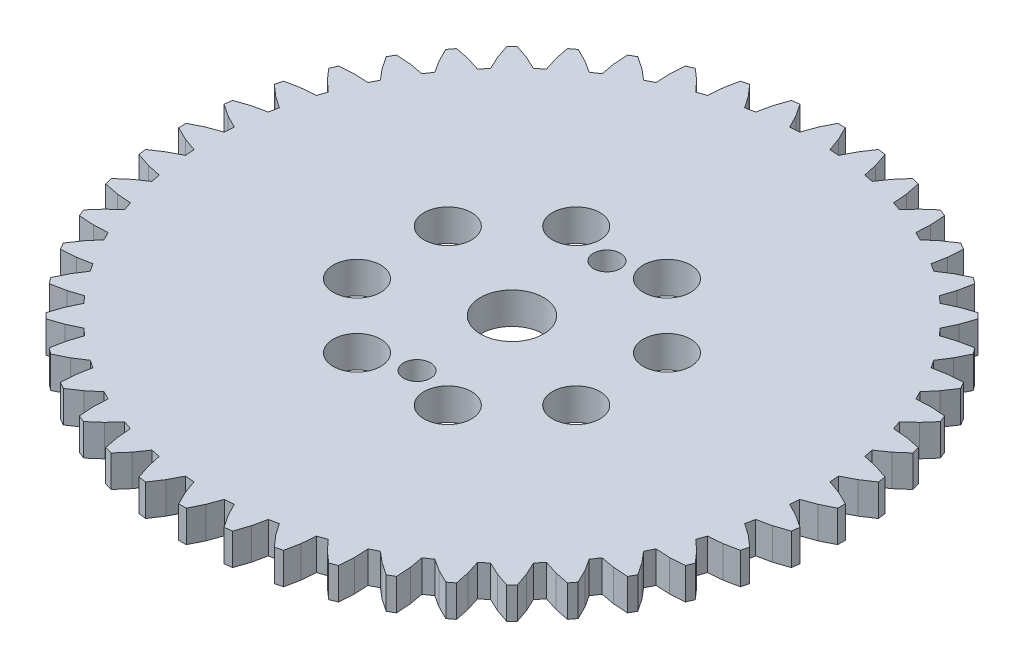
from build123d import *

# Parameters (mm, degrees)
BOSS_EXTRUDE2_DEPTH = 4
CUT_EXTRUDE1_REACH  = 6
SKETCH3_R           = 4
CUT_EXTRUDE2_REACH  = 6
SKETCH4_R           = 1.7
SKETCH5_R           = 3
CUT_EXTRUDE3_DEPTH  = 4
CIRPATTERN1_COUNT   = 8


with BuildPart() as part:
    # Sketch1 → Boss-Extrude2 (new body)
    with BuildSketch(Plane(origin=(0, 0, 0), x_dir=(1, 0, 0), z_dir=(0, 1, 0))):
        Polygon((42.670768214, 7.33199203), (44.364090179, 6.722783745), (46.049296244, 5.897590381), (46.049296244, 4.930501415), (44.364090179, 4.10530805), (42.670768214, 3.496099765), (42.593668553, 2.318392566), (44.192872884, 1.493330462), (45.756080243, 0.455162666), (45.629761993, -0.503548343), (43.851224003, -1.101761341), (42.092976227, -1.484774504), (41.862723156, -2.64232275), (43.340583693, -3.668971144), (44.754826389, -4.902310618), (44.504546088, -5.836412796), (42.663045168, -6.197303661), (40.869846795, -6.347576757), (40.490498727, -7.465069617), (41.821751264, -8.676025199), (43.062944581, -10.083330557), (42.692890512, -10.976722901), (40.819973758, -11.094271266), (39.022455841, -11.009186038), (38.500557723, -12.067643121), (39.662294716, -13.441830895), (40.709232397, -14.999147756), (40.225688377, -15.836645304), (38.353556868, -15.7087561), (36.582480794, -15.389753168), (35.926802973, -16.37097933), (36.899389583, -17.885098897), (37.734007744, -19.56572336), (37.14535034, -20.332928251), (35.305944489, -19.96169562), (33.591678325, -19.414272165), (32.813478148, -20.30164275), (33.58002859, -21.929645586), (34.188189572, -23.704910872), (33.504368159, -24.388732285), (31.729102873, -23.780570839), (30.101100501, -23.01402086), (29.213729452, -23.792221038), (29.761152907, -25.506486738), (30.132385538, -27.345893053), (29.365180648, -27.934549993), (27.684556184, -27.099932296), (26.170436617, -26.127345222), (25.189210455, -26.783023506), (25.508213387, -28.554099581), (25.636103055, -30.426230626), (24.798605043, -30.90977511), (23.241288182, -29.862837428), (21.867100409, -28.701100436), (20.808643325, -29.222998554), (20.893728553, -31.020516471), (20.776180188, -32.893433225), (19.882787844, -33.263487293), (18.475482486, -32.022293977), (17.264527368, -30.69104144), (16.147034045, -31.070389508), (15.996760948, -32.863587881), (15.635870083, -34.705088337), (14.701767905, -34.955369102), (13.468428431, -33.541125942), (12.441780037, -32.063265869), (11.284231792, -32.293518476), (10.901218628, -34.051766716), (10.30300563, -35.830304706), (9.344294621, -35.956622956), (8.306126825, -34.393415597), (7.481064721, -32.794210802), (6.303357522, -32.871310927), (5.694149237, -34.564632892), (4.868955873, -36.249838957), (3.901866906, -36.249838957), (3.076674006, -34.564632892), (2.467465257, -32.871310927), (1.289758521, -32.794210802), (0.464695954, -34.393415597), (-0.573471379, -35.956622956), (-1.532182851, -35.830304706), (-2.130395385, -34.051766716), (-2.513408549, -32.293518476), (-3.670957258, -32.063265869), (-4.697605189, -33.541125942), (-5.930944663, -34.955369102), (-6.865046841, -34.705088337), (-7.22593817, -32.863587881), (-7.376211266, -31.070389508), (-8.493704125, -30.69104144), (-9.704659707, -32.022293977), (-11.111965066, -33.263487293), (-12.005356946, -32.893433225), (-12.122905311, -31.020516471), (-12.037820547, -29.222998554), (-13.096277166, -28.701100436), (-14.470464939, -29.862837428), (-16.0277818, -30.90977511), (-16.865279812, -30.426230626), (-16.737390608, -28.554099581), (-16.418387213, -26.783023506), (-17.399613375, -26.127345222), (-18.913732941, -27.099932296), (-20.594357869, -27.934549993), (-21.361562296, -27.345893053), (-20.990330128, -25.506486738), (-20.442906209, -23.792221038), (-21.330277258, -23.01402086), (-22.958280095, -23.780570839), (-24.733544916, -24.388732285), (-25.41736633, -23.704910872), (-24.809205347, -21.929645586), (-24.042655369, -20.30164275), (-24.820855546, -19.414272165), (-26.535121247, -19.96169562), (-28.374527561, -20.332928251), (-28.963184502, -19.56572336), (-28.128566341, -17.885098897), (-27.155979731, -16.37097933), (-27.811657551, -15.389753168), (-29.582734089, -15.7087561), (-31.454865135, -15.836645304), (-31.938409618, -14.999147756), (-30.891471473, -13.441830895), (-29.72973448, -12.067643121), (-30.251632599, -11.009186038), (-32.049150979, -11.094271266), (-33.92206727, -10.976722901), (-34.292121802, -10.083330557), (-33.050928022, -8.676025199), (-31.719675485, -7.465069617), (-32.099023553, -6.347576757), (-33.89222239, -6.197303661), (-35.733722846, -5.836412796), (-35.98400361, -4.902310618), (-34.569760451, -3.668971144), (-33.091899913, -2.64232275), (-33.322152985, -1.484774504), (-35.080401224, -1.101761341), (-36.858938751, -0.503548343), (-36.985257465, 0.455162666), (-35.422050106, 1.493330462), (-33.822845311, 2.318392566), (-33.899945435, 3.496099765), (-35.593266937, 4.10530805), (-37.278473002, 4.930501415), (-37.278473002, 5.897590381), (-35.593266937, 6.722783745), (-33.899945435, 7.33199203), (-33.822845311, 8.509698766), (-35.422050106, 9.334761333), (-36.985257465, 10.372928666), (-36.858938751, 11.331640138), (-35.080401224, 11.929852672), (-33.322152985, 12.3128663), (-33.091899913, 13.470414546), (-34.569760451, 14.49706294), (-35.98400361, 15.73040195), (-35.733722846, 16.664504128), (-33.89222239, 17.025395457), (-32.099023553, 17.175668553), (-31.719675485, 18.293161413), (-33.050928022, 19.504116994), (-34.292121802, 20.911422353), (-33.92206727, 21.804814697), (-32.049150979, 21.922362598), (-30.251632599, 21.837277834), (-29.72973448, 22.895734917), (-30.891471473, 24.269922226), (-31.938409618, 25.827239088), (-31.454865135, 26.664737099), (-29.582734089, 26.536847895), (-27.811657551, 26.2178445), (-27.155979731, 27.199070662), (-28.128566341, 28.713190692), (-28.963184502, 30.393815156), (-28.374527561, 31.161019583), (-26.535121247, 30.789787415), (-24.820855546, 30.24236396), (-24.042655369, 31.129734545), (-24.809205347, 32.757737382), (-25.41736633, 34.533002667), (-24.733544916, 35.216823617), (-22.958280095, 34.608662635), (-21.330277258, 33.842112656), (-20.442906209, 34.620312834), (-20.990330128, 36.334578534), (-21.361562296, 38.173984848), (-20.594357869, 38.762641789), (-18.913732941, 37.928023628), (-17.399613375, 36.955437018), (-16.418387213, 37.611114838), (-16.737390608, 39.382191376), (-16.865279812, 41.254322422), (-16.0277818, 41.737866905), (-14.470464939, 40.690929224), (-13.096277166, 39.529191768), (-12.037820547, 40.051089886), (-12.122905311, 41.848608266), (-12.005356946, 43.721524557), (-11.111965066, 44.091579089), (-9.704659707, 42.850385772), (-8.493704125, 41.519133236), (-7.376211266, 41.898481304), (-7.22593817, 43.691679677), (-6.865046841, 45.533180133), (-5.930944663, 45.783460897), (-4.697605189, 44.369217738), (-3.670957258, 42.891357201), (-2.513408549, 43.121610272), (-2.130395385, 44.879858512), (-1.532182851, 46.658396038), (-0.573471379, 46.784714752), (0.464695954, 45.221507393), (1.289758521, 43.622302598), (2.467465257, 43.699402722), (3.076674006, 45.392724688), (3.901866906, 47.077930289), (4.868955873, 47.077930289), (5.694149237, 45.392724688), (6.303357522, 43.699402722), (7.481064721, 43.622302598), (8.306126825, 45.221507393), (9.344294621, 46.784714752), (10.30300563, 46.658396038), (10.901218628, 44.879858512), (11.284231792, 43.121610272), (12.441780037, 42.891357201), (13.468428431, 44.369217738), (14.701767905, 45.783460897), (15.635870083, 45.533180133), (15.996760948, 43.691679677), (16.147034045, 41.898481304), (17.264527368, 41.519133236), (18.475482486, 42.850385772), (19.882787844, 44.091579089), (20.776180188, 43.721524557), (20.893728553, 41.848608266), (20.808643325, 40.051089886), (21.867100409, 39.529191768), (23.241288182, 40.690929224), (24.798605043, 41.737866905), (25.636103055, 41.254322422), (25.508213387, 39.382191376), (25.189210455, 37.611114838), (26.170436617, 36.955437018), (27.684556184, 37.928023628), (29.365180648, 38.762641789), (30.132385538, 38.173984848), (29.761152907, 36.334578534), (29.213729452, 34.620312834), (30.101100501, 33.842112656), (31.729102873, 34.608662635), (33.504368159, 35.216823617), (34.188189572, 34.533002667), (33.58002859, 32.757737382), (32.813478148, 31.129734545), (33.591678325, 30.24236396), (35.305944489, 30.789787415), (37.14535034, 31.161019583), (37.734007744, 30.393815156), (36.899389583, 28.713190692), (35.926802973, 27.199070662), (36.582480794, 26.2178445), (38.353556868, 26.536847895), (40.225688377, 26.664737099), (40.709232397, 25.827239088), (39.662294716, 24.269922226), (38.500557723, 22.895734917), (39.022455841, 21.837277834), (40.819973758, 21.922362598), (42.692890512, 21.804814697), (43.062944581, 20.911422353), (41.821751264, 19.504116994), (40.490498727, 18.293161413), (40.869846795, 17.175668553), (42.663045168, 17.025395457), (44.504546088, 16.664504128), (44.754826389, 15.73040195), (43.340583693, 14.49706294), (41.862723156, 13.470414546), (42.092976227, 12.3128663), (43.851224003, 11.929852672), (45.629761993, 11.331640138), (45.756080243, 10.372928666), (44.192872884, 9.334761333), (42.593668553, 8.509698766), align=None)
    extrude(amount=BOSS_EXTRUDE2_DEPTH)

    # Sketch3 → Cut-Extrude1 (cut, up to next)
    with BuildSketch(Plane(origin=(0, 0, 0), x_dir=(1, 0, 0), z_dir=(0, 1, 0)), mode=Mode.PRIVATE) as cut_extrude1_sk1:
        with Locations((4.385411621, 5.414045898)):
            Circle(SKETCH3_R)
    cut_extrude1_tool1 = extrude(cut_extrude1_sk1.sketch, amount=CUT_EXTRUDE1_REACH, mode=Mode.PRIVATE) & part.part
    add(cut_extrude1_tool1.solids().sort_by_distance((4.385412, 0, -5.414046))[0], mode=Mode.SUBTRACT)

    # Sketch4 → Cut-Extrude2 (cut, up to next)
    with BuildSketch(Plane(origin=(0, 0, 0), x_dir=(1, 0, 0), z_dir=(0, 1, 0)), mode=Mode.PRIVATE) as cut_extrude2_sk1:
        with Locations((4.385411389, 17.414045898)):
            Circle(SKETCH4_R)
    cut_extrude2_tool1 = extrude(cut_extrude2_sk1.sketch, amount=CUT_EXTRUDE2_REACH, mode=Mode.PRIVATE) & part.part
    add(cut_extrude2_tool1.solids().sort_by_distance((4.385411, 0, -17.414046))[0], mode=Mode.SUBTRACT)
    # Sketch4 → Cut-Extrude2 (cut, up to next)
    with BuildSketch(Plane(origin=(0, 0, 0), x_dir=(1, 0, 0), z_dir=(0, 1, 0)), mode=Mode.PRIVATE) as cut_extrude2_sk2:
        with Locations((4.385411389, -6.585954102)):
            Circle(SKETCH4_R)
    cut_extrude2_tool2 = extrude(cut_extrude2_sk2.sketch, amount=CUT_EXTRUDE2_REACH, mode=Mode.PRIVATE) & part.part
    add(cut_extrude2_tool2.solids().sort_by_distance((4.385411, 0, 6.585954))[0], mode=Mode.SUBTRACT)

    # Sketch5 → Cut-Extrude3 (cut)
    with BuildSketch(Plane(origin=(0, 0, 0), x_dir=(1, 0, 0), z_dir=(0, 1, 0))):
        with Locations((10.125663107, 19.272238885)):
            Circle(SKETCH5_R)
    cut_extrude3 = extrude(amount=CUT_EXTRUDE3_DEPTH, mode=Mode.SUBTRACT)

    # CirPattern1: Cut-Extrude3 ×8 about axis
    cirpattern1_axis = Axis((4.385411621, 0, -5.414045898), (0, 1, 0))
    for i in range(1, CIRPATTERN1_COUNT):
        add(cut_extrude3.rotate(cirpattern1_axis, i * 360 / CIRPATTERN1_COUNT), mode=Mode.SUBTRACT)


solid = part.part
